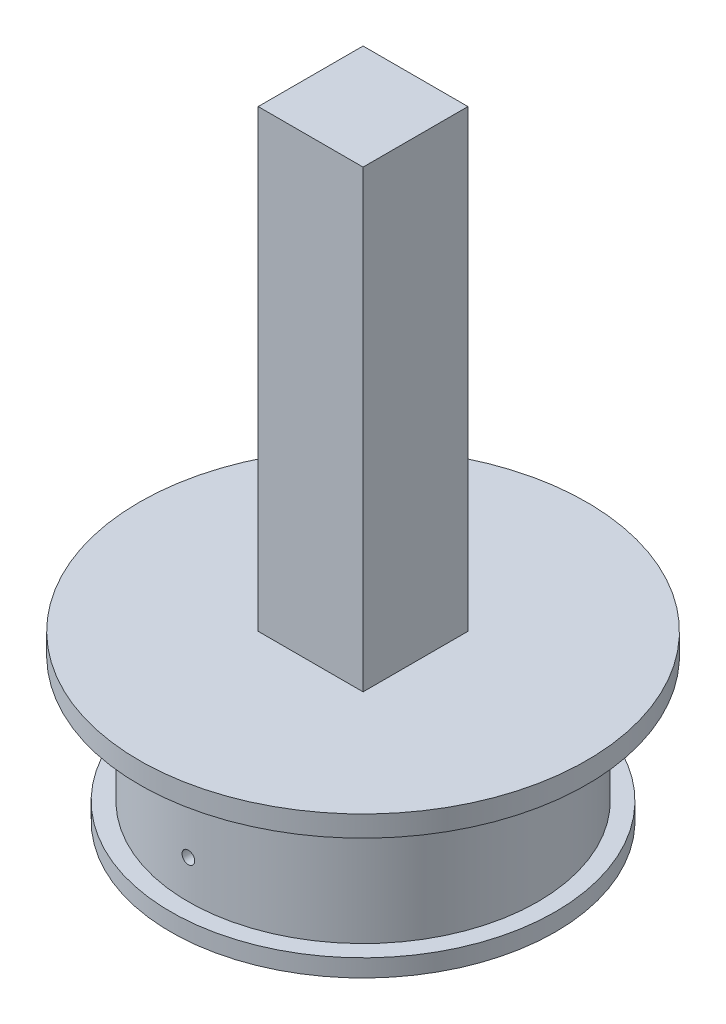
from build123d import *

# Parameters (mm, degrees)
SKETCH2_W               = 5
SKETCH2_H               = 74.664160083
SKETCH2_W_2             = 10
SKETCH2_H_2             = 5
SKETCH2_R               = 1.15
BOSS_EXTRUDE1_DEPTH     = 1.5
SKETCH3_W               = 13
SKETCH3_H               = 74.664160083
BOSS_EXTRUDE2_DEPTH     = 1
SKETCH5_W               = 97.96
SKETCH5_H               = 74.648794292
BOSS_EXTRUDE3_DEPTH     = 1
SKETCH6_R               = 25
SKETCH6_R_2             = 23
BOSS_EXTRUDE4_DEPTH     = 18
SKETCH8_R               = 27.5
SKETCH8_R_2             = 23.5
BOSS_EXTRUDE6_DEPTH     = 2.5
SKETCH13_W              = 18
SKETCH13_H              = 23
BOSS_EXTRUDE7_DEPTH     = 1
SKETCH15_R              = 3.75
CUT_EXTRUDE3_DEPTH      = 1
BODY_MOVE_COPY2_ANGLE   = 90
SKETCH16_R              = 3.75
BOSS_EXTRUDE8_DEPTH     = 6
SKETCH17_R              = 0.9
CUT_EXTRUDE4_DEPTH      = 46
CUT_EXTRUDE4_DEPTH_BACK = 44
SKETCH18_W              = 142.524598678
SKETCH18_H              = 112.115255427
CUT_EXTRUDE5_DEPTH      = 7
SKETCH20_R              = 32
BOSS_EXTRUDE9_DEPTH     = 3
SKETCH23_W              = 15
SKETCH23_H              = 15
BOSS_EXTRUDE11_DEPTH    = 65


with BuildPart() as part:
    # Sketch2 → Boss-Extrude1 (new body)
    with BuildSketch(Plane.XY):
        with Locations((376.369557123, 140.674264472)):
            Rectangle(SKETCH2_W, SKETCH2_H)
        with Locations((368.869557123, 175.506344513)):
            Rectangle(SKETCH2_W_2, SKETCH2_H_2)
        with Locations((366.369557123, 175.506344513)):
            Circle(SKETCH2_R, mode=Mode.SUBTRACT)
        with Locations((368.869557123, 105.84218443)):
            Rectangle(SKETCH2_W_2, SKETCH2_H_2)
        with Locations((366.369557123, 105.84218443)):
            Circle(SKETCH2_R, mode=Mode.SUBTRACT)
    boss_extrude1 = extrude(amount=BOSS_EXTRUDE1_DEPTH)

    # Sketch3 → Boss-Extrude2 (add)
    with BuildSketch(Plane(origin=(378.869557123, 0, 0), x_dir=(0, 0, -1), z_dir=(1, 0, 0))):
        with Locations((5, 140.674264472)):
            Rectangle(SKETCH3_W, SKETCH3_H)
    extrude(amount=BOSS_EXTRUDE2_DEPTH)

    # Mirror3: Boss-Extrude1 across plane
    add(boss_extrude1.mirror(Plane(origin=(0, 0, -5), x_dir=(1, 0, 0), z_dir=(0, 0, -1))))


with BuildPart() as body_2:
    # Body-Move/Copy1: copy of part
    add(part.part.moved(Location((0, 0, 84.96))))


with BuildPart() as part_1:
    add(part.part)

    add(body_2.part)  # Boss-Extrude3 merges body 2
    # Sketch5 → Boss-Extrude3 (add)
    with BuildSketch(Plane(origin=(379.869557123, 0, 0), x_dir=(0, 0, -1), z_dir=(1, 0, 0))):
        with Locations((-37.48, 140.681947367)):
            Rectangle(SKETCH5_W, SKETCH5_H)
    extrude(amount=-BOSS_EXTRUDE3_DEPTH)

    # Sketch6 → Boss-Extrude4 (add)
    with BuildSketch(Plane.ZY.offset(-378.869557123)):
        with Locations(Location((37.48, 140.674264472, 0), (0, 0, 270))):
            Circle(SKETCH6_R)
        with Locations(Location((37.48, 140.674264472, 0), (0, 0, 270))):
            Circle(SKETCH6_R_2, mode=Mode.SUBTRACT)
    extrude(amount=BOSS_EXTRUDE4_DEPTH)

    # Sketch8 → Boss-Extrude6 (add)
    with BuildSketch(Plane.ZY.offset(-360.869557123)):
        with Locations(Location((37.48, 140.674264472, 0), (0, 0, 270))):
            Circle(SKETCH8_R)
        with Locations(Location((37.48, 140.674264472, 0), (0, 0, 270))):
            Circle(SKETCH8_R_2, mode=Mode.SUBTRACT)
    extrude(amount=BOSS_EXTRUDE6_DEPTH)

    # Sketch13 → Boss-Extrude7 (add)
    with BuildSketch(Plane.ZY.offset(-378.869557123)):
        with Locations((37.48, 189.506344513)):
            Rectangle(SKETCH13_W, SKETCH13_H)
        with Locations((37.48, 91.857550221)):
            Rectangle(SKETCH13_W, SKETCH13_H)
    extrude(amount=-BOSS_EXTRUDE7_DEPTH)

    # Sketch15 → Cut-Extrude3 (cut)
    with BuildSketch(Plane.ZY.offset(-378.869557123)):
        with Locations(Location((37.48, 195.006344513, 0), (0, 0, 270))):
            Circle(SKETCH15_R)
        with Locations(Location((37.48, 86.357550221, 0), (0, 0, 270))):
            Circle(SKETCH15_R)
    extrude(amount=-CUT_EXTRUDE3_DEPTH, mode=Mode.SUBTRACT)


with BuildPart() as part_2:
    # Body-Move/Copy2: moved
    add(part_1.part.rotate(Axis((371.869557123, 140.681947367, 0), (0, 0, 1)), BODY_MOVE_COPY2_ANGLE))

    # Sketch16 → Boss-Extrude8 (add)
    with BuildSketch(Plane(origin=(0, 148.681947367, 0), x_dir=(1, 0, 0), z_dir=(0, 1, 0))):
        Polygon((334.545159977, -28.48), (334.545159977, 11.5), (409.20932006, 11.5), (409.193954269, -28.48), (432.193954269, -28.48), (432.193954269, -46.48), (409.193954269, -46.48), (409.20932006, -86.46), (334.545159977, -86.46), (334.545159977, -46.48), (311.545159977, -46.48), (311.545159977, -28.48), align=None)
        with Locations((317.545159977, -37.48)):
            Circle(SKETCH16_R, mode=Mode.SUBTRACT)
        with Locations((426.193954269, -37.48)):
            Circle(SKETCH16_R, mode=Mode.SUBTRACT)
    extrude(amount=BOSS_EXTRUDE8_DEPTH)

    # Sketch17 → Cut-Extrude4 (cut, two sides)
    with BuildSketch(Plane.XY.offset(37.48)) as cut_extrude4_sk:
        with Locations(Location((371.877240018, 135.181947367, 0), (0, 0, 180))):
            Circle(SKETCH17_R)
    extrude(amount=CUT_EXTRUDE4_DEPTH, mode=Mode.SUBTRACT)
    extrude(cut_extrude4_sk.sketch, amount=-CUT_EXTRUDE4_DEPTH_BACK, mode=Mode.SUBTRACT)

    # Sketch18 → Cut-Extrude5 (cut)
    with BuildSketch(Plane(origin=(0, 154.681947367, 0), x_dir=(1, 0, 0), z_dir=(0, 1, 0))):
        with Locations((368.644323748, -41.089189729)):
            Rectangle(SKETCH18_W, SKETCH18_H)
    extrude(amount=-CUT_EXTRUDE5_DEPTH, mode=Mode.SUBTRACT)


with BuildPart() as body_2_2:
    # of the pieces the cut leaves, the one that is kept (cut_extrude5_keep)
    add(part_2.part.solids().sort_by_distance((396.877240018, 147.681947367, 37.48))[0])

    # Sketch20 → Boss-Extrude9 (add)
    with BuildSketch(Plane(origin=(0, 147.681947367, 0), x_dir=(1, 0, 0), z_dir=(0, 1, 0))):
        with Locations(Location((371.877240018, -37.48, 0), (0, 0, 180))):
            Circle(SKETCH20_R)
    extrude(amount=BOSS_EXTRUDE9_DEPTH)

    # Sketch23 → Boss-Extrude11 (add)
    with BuildSketch(Plane(origin=(0, 150.681947367, 0), x_dir=(1, 0, 0), z_dir=(0, 1, 0))):
        with Locations((371.877240018, -37.48)):
            Rectangle(SKETCH23_W, SKETCH23_H)
    extrude(amount=BOSS_EXTRUDE11_DEPTH)


solid = body_2_2.part
